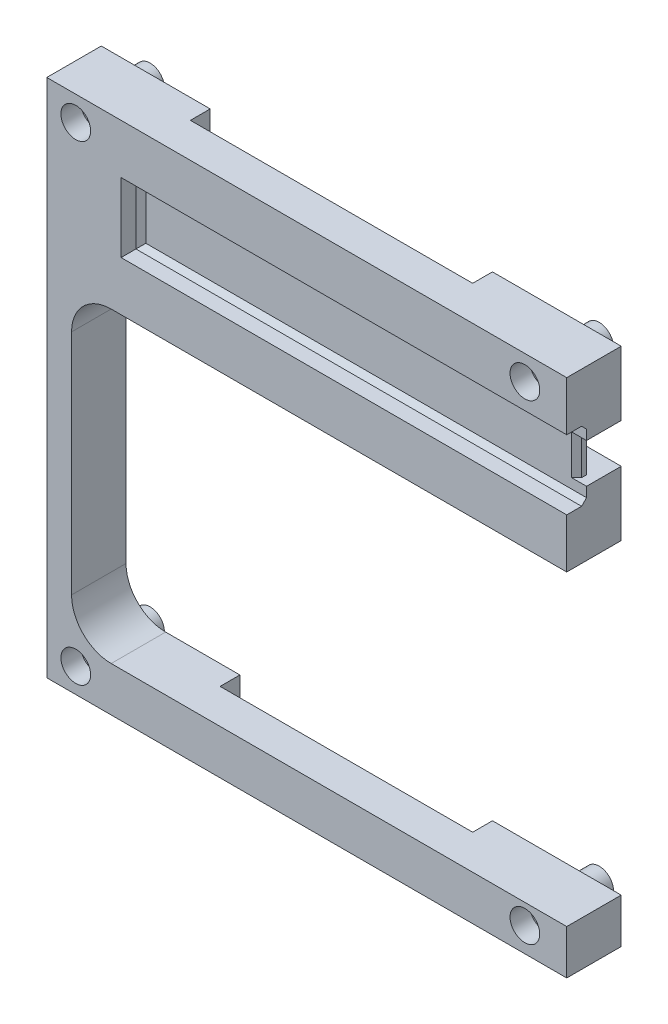
from build123d import *

# Parameters (mm, degrees)
SKETCH_1_W           = 105
SKETCH_1_H           = 105
EXTRUDE_1_DEPTH      = 15
SKETCH_2_R           = 1.6
CUT_EXTRUDE_1_DEPTH  = 15
SKETCH_3_W           = 100
SKETCH_3_H           = 62
CUT_EXTRUDE_2_DEPTH  = 15
FILLET_1_R           = 8
SKETCH_4_OUTSIDE_W   = 136.85
SKETCH_4_OUTSIDE_H   = 136.85
SKETCH_4_OUTSIDE_R   = 2.9
CUT_EXTRUDE_3_DEPTH  = 4
SKETCH_5_W           = 51
SKETCH_5_H           = 9
CUT_EXTRUDE_4_DEPTH  = 4
SKETCH_6_W           = 57
SKETCH_6_H           = 34
CUT_EXTRUDE_5_DEPTH  = 4
CUT_EXTRUDE_6_DEPTH  = 4
FILLET_2_R           = 4
SKETCH_8_W           = 90
SKETCH_8_H           = 14
CUT_EXTRUDE_7_DEPTH  = 4
CHAMFER_1_SIZE       = 1
SKETCH_9_W           = 2
SKETCH_9_H           = 8
CUT_EXTRUDE_8_DEPTH  = 4
CHAMFER_2_SIZE       = 1
SKETCH_10_R          = 3
CUT_EXTRUDE_9_DEPTH  = 4
CUT_EXTRUDE_10_DEPTH = 5
FILLET_3_R           = 2


with BuildPart() as part:
    # 草图1 → 凸台-拉伸1 (new body)
    with BuildSketch(Plane.XY):
        Rectangle(SKETCH_1_W, SKETCH_1_H)
    extrude(amount=EXTRUDE_1_DEPTH)

    # 草图2 → 切除-拉伸1 (cut)
    with BuildSketch(Plane.XY.offset(15)):
        with Locations((-46.65, 47.555)):
            Circle(SKETCH_2_R)
        with Locations((44.05, 47.555)):
            Circle(SKETCH_2_R)
        with Locations((44.05, -47.555)):
            Circle(SKETCH_2_R)
        with Locations((-46.65, -47.555)):
            Circle(SKETCH_2_R)
    extrude(amount=-CUT_EXTRUDE_1_DEPTH, mode=Mode.SUBTRACT)

    # 草图3 → 切除-拉伸2 (cut)
    with BuildSketch(Plane.XY.offset(15)):
        with Locations((2.5, -12.5)):
            Rectangle(SKETCH_3_W, SKETCH_3_H)
    extrude(amount=-CUT_EXTRUDE_2_DEPTH, mode=Mode.SUBTRACT)

    # 圆角1
    fillet_1_edges = [part.edges().sort_by_distance(p)[0] for p in [
        (-47.5, -43.5, 7.5),
        (-47.5, 18.5, 7.5),
    ]]
    fillet(fillet_1_edges, radius=FILLET_1_R)

    # 草图4 outside → 切除-拉伸3 (cut)
    with BuildSketch(Plane(origin=(0, 0, 0), x_dir=(-1, 0, 0), z_dir=(0, 0, -1))):
        Rectangle(SKETCH_4_OUTSIDE_W, SKETCH_4_OUTSIDE_H)
        with Locations((-44.05, -47.555)):
            Circle(SKETCH_4_OUTSIDE_R, mode=Mode.SUBTRACT)
        with Locations((46.65, -47.555)):
            Circle(SKETCH_4_OUTSIDE_R, mode=Mode.SUBTRACT)
        with Locations((-44.05, 47.555)):
            Circle(SKETCH_4_OUTSIDE_R, mode=Mode.SUBTRACT)
        with Locations((46.65, 47.555)):
            Circle(SKETCH_4_OUTSIDE_R, mode=Mode.SUBTRACT)
    extrude(amount=-CUT_EXTRUDE_3_DEPTH, mode=Mode.SUBTRACT)

    # 草图5 → 切除-拉伸4 (cut)
    with BuildSketch(Plane(origin=(0, 0, 4), x_dir=(-1, 0, 0), z_dir=(0, 0, -1))):
        with Locations((-1, -48)):
            Rectangle(SKETCH_5_W, SKETCH_5_H)
    extrude(amount=-CUT_EXTRUDE_4_DEPTH, mode=Mode.SUBTRACT)

    # 草图6 → 切除-拉伸5 (cut)
    with BuildSketch(Plane(origin=(0, 0, 4), x_dir=(-1, 0, 0), z_dir=(0, 0, -1))):
        with Locations((2, 35.5)):
            Rectangle(SKETCH_6_W, SKETCH_6_H)
    extrude(amount=-CUT_EXTRUDE_5_DEPTH, mode=Mode.SUBTRACT)

    # 草图7 → 切除-拉伸6 (cut)
    with BuildSketch(Plane(origin=(0, 0, 4), x_dir=(-1, 0, 0), z_dir=(0, 0, -1))):
        Polygon((-26.5, 35.5), (-26.5, 39.5), (-52.5, 39.5), (-52.5, 31.5), (-26.5, 31.5), align=None)
    extrude(amount=-CUT_EXTRUDE_6_DEPTH, mode=Mode.SUBTRACT)

    # 圆角2
    fillet_2_edges = [part.edges().sort_by_distance(p)[0] for p in [
        (26.5, 39.5, 6),
        (26.5, 31.5, 6),
    ]]
    fillet(fillet_2_edges, radius=FILLET_2_R)

    # 草图8 → 切除-拉伸7 (cut)
    with BuildSketch(Plane.XY.offset(15)):
        with Locations((7.5, 35.5)):
            Rectangle(SKETCH_8_W, SKETCH_8_H)
    extrude(amount=-CUT_EXTRUDE_7_DEPTH, mode=Mode.SUBTRACT)

    # 倒角1
    chamfer_1_edges = [part.edges().sort_by_distance(p)[0] for p in [
        (7.5, 42.5, 11),
        (7.5, 28.5, 11),
        (-37.5, 35.5, 11),
    ]]
    chamfer(chamfer_1_edges, length=CHAMFER_1_SIZE)

    # 草图9 → 切除-拉伸8 (cut)
    with BuildSketch(Plane(origin=(0, 0, 8), x_dir=(-1, 0, 0), z_dir=(0, 0, -1))):
        with Locations((-51.5, 35.5)):
            Rectangle(SKETCH_9_W, SKETCH_9_H)
    extrude(amount=-CUT_EXTRUDE_8_DEPTH, mode=Mode.SUBTRACT)

    # 倒角2
    chamfer_2_edges = [part.edges().sort_by_distance(p)[0] for p in [
        (50.5, 35.5, 11),
        (50.5, 35.5, 8),
    ]]
    chamfer(chamfer_2_edges, length=CHAMFER_2_SIZE)

    # 草图10 → 切除-拉伸9 (cut)
    with BuildSketch(Plane.XY.offset(15)):
        with Locations((-46.65, 47.555)):
            Circle(SKETCH_10_R)
        with Locations((44.05, 47.555)):
            Circle(SKETCH_10_R)
        with Locations((44.05, -47.555)):
            Circle(SKETCH_10_R)
        with Locations((-46.65, -47.555)):
            Circle(SKETCH_10_R)
    extrude(amount=-CUT_EXTRUDE_9_DEPTH, mode=Mode.SUBTRACT)

    # 草图11 → 切除-拉伸10 (cut)
    with BuildSketch(Plane(origin=(0, 0, 4), x_dir=(-1, 0, 0), z_dir=(0, 0, -1))):
        with BuildLine():
            Line((33.5, 49.5), (41.079813737, 49.5))
            ThreePointArc((41.079813737, 49.5), (42.843240971, 43.047385809), (49.5, 42.38900542))
            Line((49.5, 42.38900542), (49.5, 21.5))
            Line((49.5, 21.5), (33.5, 21.5))
            Line((33.5, 21.5), (33.5, 49.5))
        make_face()
    extrude(amount=-CUT_EXTRUDE_10_DEPTH, mode=Mode.SUBTRACT)

    # 圆角3
    fillet_3_edges = [part.edges().sort_by_distance(p)[0] for p in [
        (-42.843240971, 43.047385809, 9),
        (-49.5, 31.94450271, 9),
        (-41.5, 21.5, 9),
        (-33.5, 35.5, 9),
        (-37.289906869, 49.5, 9),
    ]]
    fillet(fillet_3_edges, radius=FILLET_3_R)


solid = part.part
